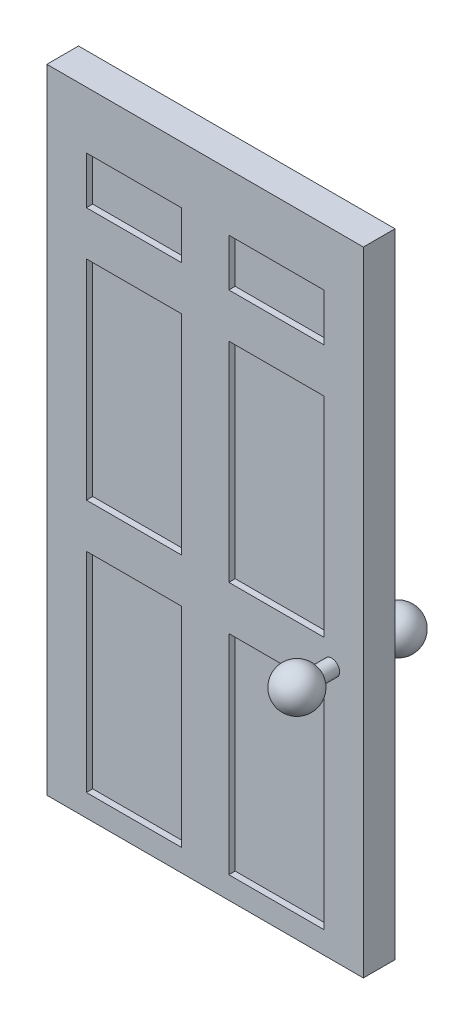
from build123d import *

# Parameters (mm, degrees)
SKETCH1_W           = 50
SKETCH1_H           = 100
BOSS_EXTRUDE1_DEPTH = 2.5
SKETCH2_R           = 1.25
BOSS_EXTRUDE2_DEPTH = 2.5
SKETCH4_W           = 15
SKETCH4_H           = 7.5
SKETCH4_H_2         = 33
CUT_EXTRUDE1_DEPTH  = 1


with BuildPart() as part:
    # Sketch1 → Boss-Extrude1 (new body, symmetric)
    with BuildSketch(Plane.XY):
        Rectangle(SKETCH1_W, SKETCH1_H)
    extrude(amount=BOSS_EXTRUDE1_DEPTH, both=True)

    # Sketch2 → Boss-Extrude2 (add)
    with BuildSketch(Plane.XY.offset(2.5)):
        with Locations((20, -10)):
            Circle(SKETCH2_R)
    boss_extrude2 = extrude(amount=BOSS_EXTRUDE2_DEPTH)

    # Sketch3 → Revolve1 (revolve)
    with BuildSketch(Plane(origin=(20, 0, 0), x_dir=(0, 0, -1), z_dir=(1, 0, 0))):
        with BuildLine():
            Line((-8, -6.75), (-8, -13.25))
            ThreePointArc((-8, -13.25), (-11.25, -10), (-8, -6.75))
        make_face()
    revolve1 = revolve(axis=Axis((20, -6.75, 8), (0, -1, 0)))

    # Sketch4 → Cut-Extrude1 (cut)
    with BuildSketch(Plane.XY.offset(2.5)):
        with Locations((-11.25, 37.25)):
            Rectangle(SKETCH4_W, SKETCH4_H)
        with Locations((11.25, 37.25)):
            Rectangle(SKETCH4_W, SKETCH4_H)
        with Locations((11.25, 10)):
            Rectangle(SKETCH4_W, SKETCH4_H_2)
        with Locations((-11.25, 10)):
            Rectangle(SKETCH4_W, SKETCH4_H_2)
        with Locations((-11.25, -30)):
            Rectangle(SKETCH4_W, SKETCH4_H_2)
        with Locations((11.25, -30)):
            Rectangle(SKETCH4_W, SKETCH4_H_2)
    cut_extrude1 = extrude(amount=-CUT_EXTRUDE1_DEPTH, mode=Mode.SUBTRACT)

    # Mirror1: Boss-Extrude2, Revolve1, Cut-Extrude1 across plane
    add(boss_extrude2.mirror(Plane.XY))
    add(revolve1.mirror(Plane.XY))
    add(cut_extrude1.mirror(Plane.XY), mode=Mode.SUBTRACT)


solid = part.part
